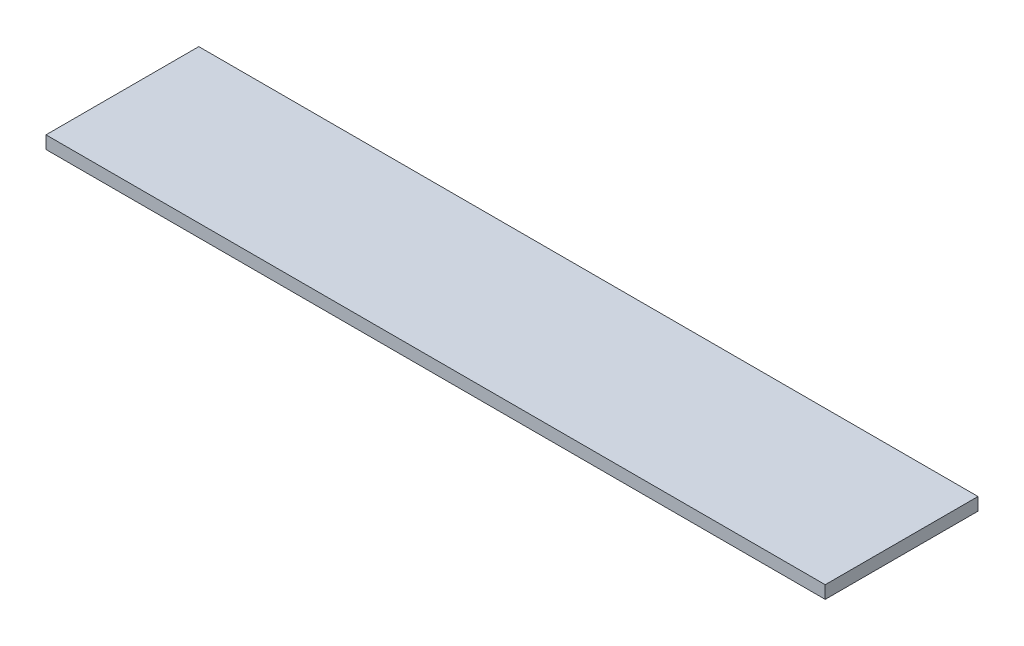
from build123d import *

# Parameters (mm, degrees)
SKETCH1_W           = 777.24
SKETCH1_H           = 152.4
BOSS_EXTRUDE1_DEPTH = 12.7


with BuildPart() as part:
    # Sketch1 → Boss-Extrude1 (new body)
    with BuildSketch(Plane(origin=(0, 0, 0), x_dir=(1, 0, 0), z_dir=(0, 1, 0))):
        Rectangle(SKETCH1_W, SKETCH1_H)
    extrude(amount=BOSS_EXTRUDE1_DEPTH)


solid = part.part
